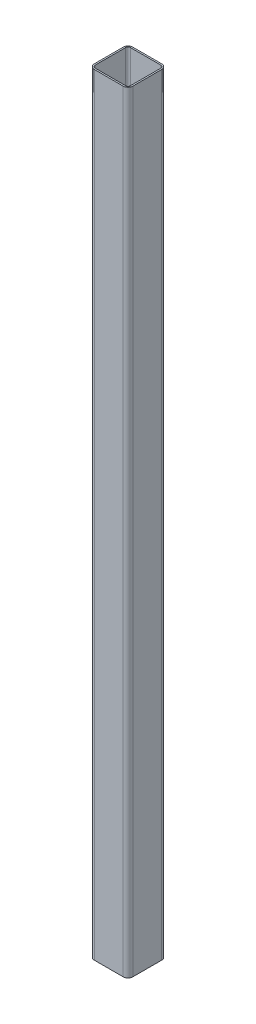
from build123d import *

# Parameters (mm, degrees)
BOSS_EXTRUDE1_DEPTH = 762


with BuildPart() as part:
    # Sketch1 → Boss-Extrude1 (new body, symmetric)
    with BuildSketch(Plane(origin=(0, 0, 0), x_dir=(1, 0, 0), z_dir=(0, 1, 0))):
        with BuildLine():
            Line((-28.575, -38.1), (28.575, -38.1))
            ThreePointArc((28.575, -38.1), (35.310192091, -35.310192091), (38.1, -28.575))
            Line((38.1, -28.575), (38.1, 28.575))
            ThreePointArc((38.1, 28.575), (35.310192091, 35.310192091), (28.575, 38.1))
            Line((28.575, 38.1), (-28.575, 38.1))
            ThreePointArc((-28.575, 38.1), (-35.310192091, 35.310192091), (-38.1, 28.575))
            Line((-38.1, 28.575), (-38.1, -28.575))
            ThreePointArc((-38.1, -28.575), (-35.310192091, -35.310192091), (-28.575, -38.1))
        make_face()
        with BuildLine():
            Line((-30.2895, -35.052), (30.2895, -35.052))
            ThreePointArc((30.2895, -35.052), (33.657096045, -33.657096045), (35.052, -30.2895))
            Line((35.052, -30.2895), (35.052, 30.2895))
            ThreePointArc((35.052, 30.2895), (33.657096045, 33.657096045), (30.2895, 35.052))
            Line((30.2895, 35.052), (-30.2895, 35.052))
            ThreePointArc((-30.2895, 35.052), (-33.657096045, 33.657096045), (-35.052, 30.2895))
            Line((-35.052, 30.2895), (-35.052, -30.2895))
            ThreePointArc((-35.052, -30.2895), (-33.657096045, -33.657096045), (-30.2895, -35.052))
        make_face(mode=Mode.SUBTRACT)
    extrude(amount=BOSS_EXTRUDE1_DEPTH, both=True)


solid = part.part
